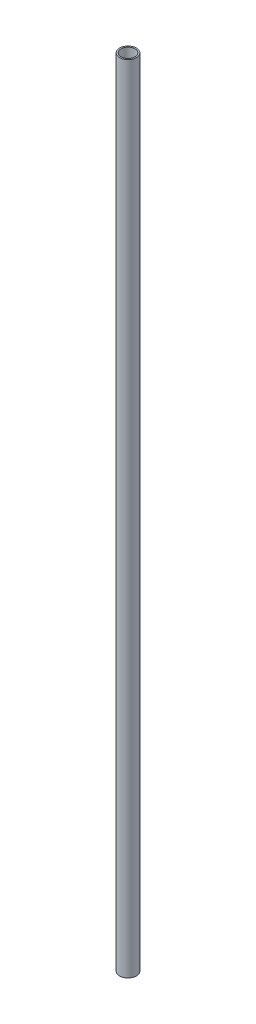
from build123d import *

# Parameters (mm, degrees)
SKETCH1_R           = 3
SKETCH1_R_2         = 2.5
BOSS_EXTRUDE1_DEPTH = 285


with BuildPart() as part:
    # Sketch1 → Boss-Extrude1 (new body)
    with BuildSketch(Plane(origin=(0, 0, 0), x_dir=(1, 0, 0), z_dir=(0, 1, 0))):
        Circle(SKETCH1_R)
        Circle(SKETCH1_R_2, mode=Mode.SUBTRACT)
    extrude(amount=BOSS_EXTRUDE1_DEPTH)


solid = part.part
